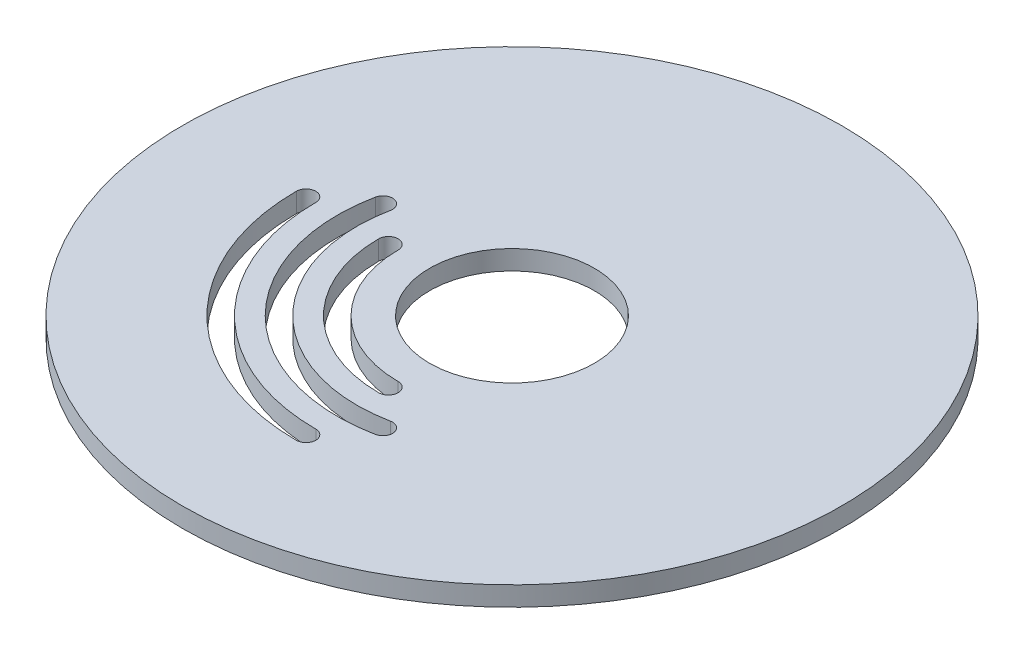
from build123d import *

# Parameters (mm, degrees)
SKETCH1_R           = 50.8
SKETCH1_R_2         = 12.7
BOSS_EXTRUDE1_DEPTH = 3


with BuildPart() as part:
    # Sketch1 → Boss-Extrude1 (new body)
    with BuildSketch(Plane(origin=(0, 0, 0), x_dir=(1, 0, 0), z_dir=(0, 1, 0))):
        Circle(SKETCH1_R)
        Circle(SKETCH1_R_2, mode=Mode.SUBTRACT)
        with BuildLine():
            ThreePointArc((-33.25, 0), (-23.511300474, -23.511300474), (0, -33.25))
            ThreePointArc((0, -33.25), (1.5, -31.75), (0, -30.25))
            ThreePointArc((0, -30.25), (-21.389980131, -21.389980131), (-30.25, 0))
            ThreePointArc((-30.25, 0), (-31.75, 1.5), (-33.25, 0))
        make_face(mode=Mode.SUBTRACT)
        with BuildLine():
            ThreePointArc((-26.373662173, 5.295275591), (-19.021172414, -19.021172414), (5.295275591, -26.373662173))
            ThreePointArc((5.295275591, -26.373662173), (6.470650307, -24.607736275), (4.704724409, -23.432361559))
            ThreePointArc((4.704724409, -23.432361559), (-16.89985207, -16.89985207), (-23.432361559, 4.704724409))
            ThreePointArc((-23.432361559, 4.704724409), (-24.607736275, 6.470650307), (-26.373662173, 5.295275591))
        make_face(mode=Mode.SUBTRACT)
        with BuildLine():
            ThreePointArc((-20.55, 0), (-14.531044353, -14.531044353), (0, -20.55))
            ThreePointArc((0, -20.55), (1.5, -19.05), (0, -17.55))
            ThreePointArc((0, -17.55), (-12.40972401, -12.40972401), (-17.55, 0))
            ThreePointArc((-17.55, 0), (-19.05, 1.5), (-20.55, 0))
        make_face(mode=Mode.SUBTRACT)
    extrude(amount=BOSS_EXTRUDE1_DEPTH)


solid = part.part
